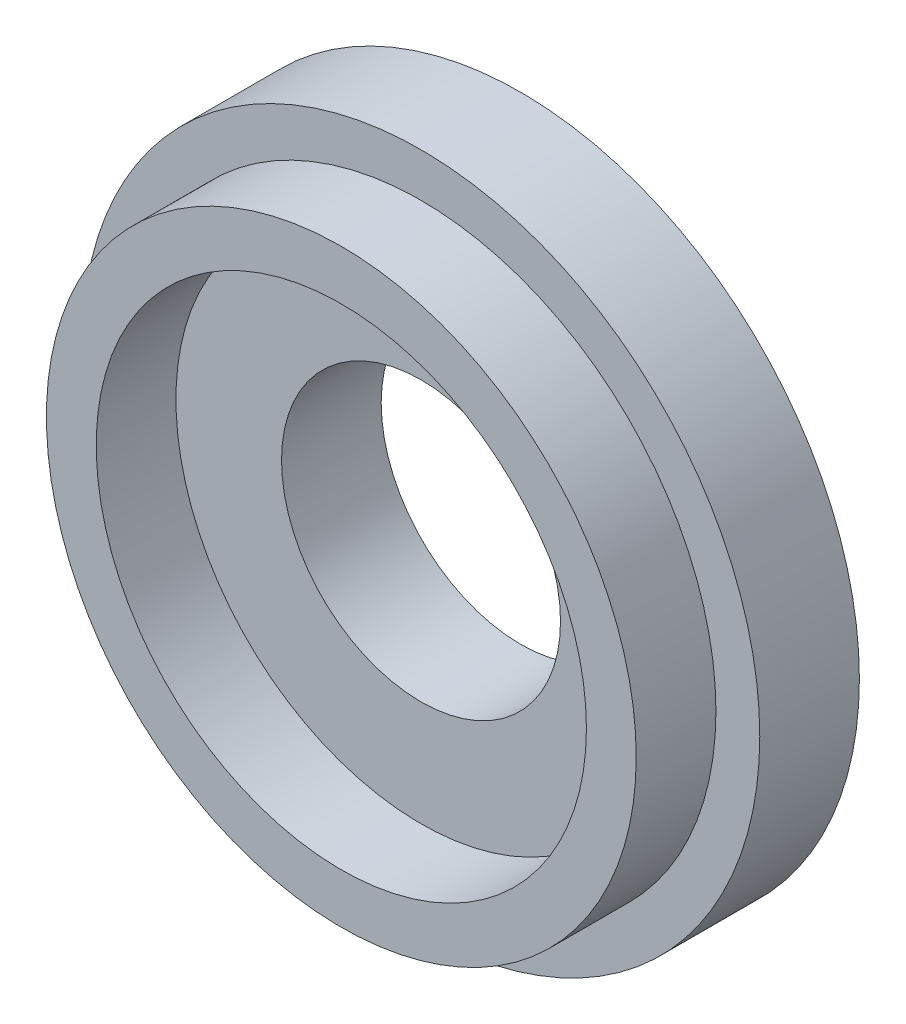
from build123d import *


with BuildPart() as part:
    # Sketch1 → Revolve1 (revolve)
    with BuildSketch(Plane(origin=(0, 0, 0), x_dir=(0, 0, -1), z_dir=(1, 0, 0))):
        Polygon((-4.409523218, 7.4), (-4.409523218, 8.5), (-1.909523218, 8.5), (-1.909523218, 3.5), (-4.409523218, 3.5), (-4.409523218, 4.25), (-4.409523218, 6.15), (-6.409523218, 6.15), (-6.409523218, 7.4), align=None)
    revolve(axis=Axis((0, 0, 52.974875508), (0, 0, -1)))


solid = part.part
